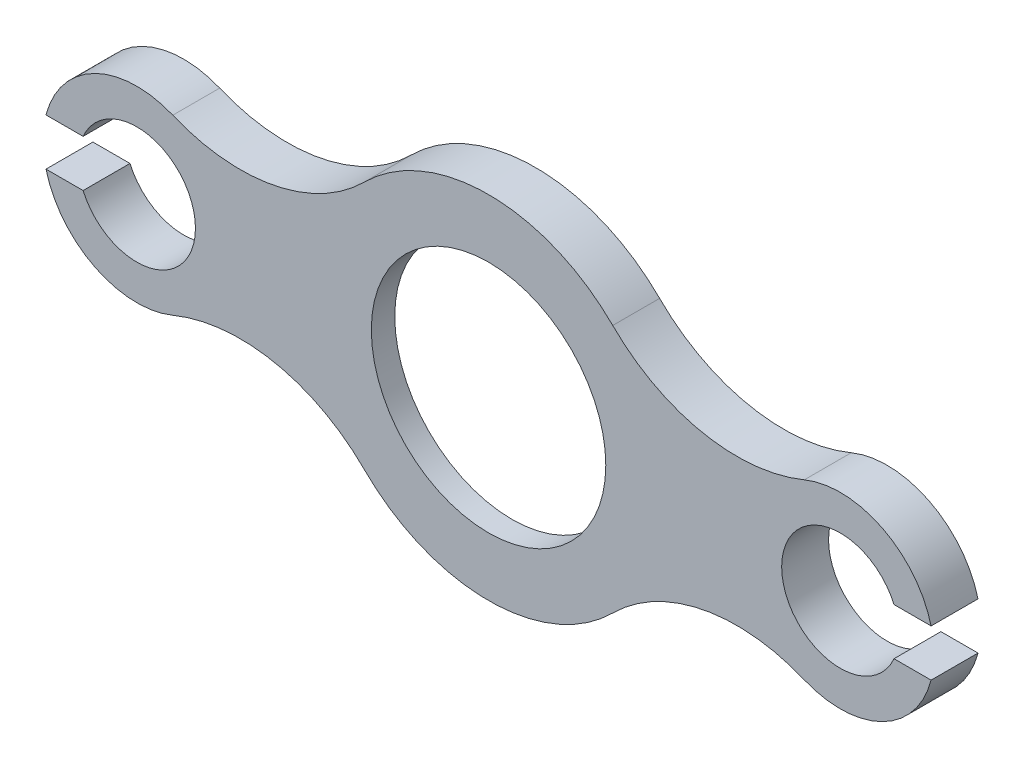
from build123d import *

# Parameters (mm, degrees)
ESQUISSE1_R             = 50
BOSS_EXTRU_1_DEPTH      = 20
ESQUISSE1_3_R           = 67.8
ESQUISSE1_3_R_2         = 50
ENL_V_MAT_EXTRU_1_DEPTH = 10


with BuildPart() as part:
    # Esquisse1 → Boss.-Extru.1 (new body)
    with BuildSketch(Plane.XY):
        with BuildLine():
            Line((-172.912878475, -10), (-188.729833462, -10))
            ThreePointArc((-188.729833462, -10), (-167.842344673, -35.800149952), (-134.666666667, -36.944402673))
            ThreePointArc((-134.666666667, -36.944402673), (-91.362529225, -32.640861336), (-52.958333333, -53.107578843))
            ThreePointArc((-52.958333333, -53.107578843), (0, -75), (52.958333333, -53.107578843))
            ThreePointArc((52.958333333, -53.107578843), (91.362529225, -32.640861336), (134.666666667, -36.944402673))
            ThreePointArc((134.666666667, -36.944402673), (167.842344673, -35.800149952), (188.729833462, -10))
            Line((188.729833462, -10), (172.912878475, -10))
            ThreePointArc((172.912878475, -10), (125, 0), (172.912878475, 10))
            Line((172.912878475, 10), (188.729833462, 10))
            ThreePointArc((188.729833462, 10), (167.842344673, 35.800149952), (134.666666667, 36.944402673))
            ThreePointArc((134.666666667, 36.944402673), (91.362529225, 32.640861336), (52.958333333, 53.107578843))
            ThreePointArc((52.958333333, 53.107578843), (0, 75), (-52.958333333, 53.107578843))
            ThreePointArc((-52.958333333, 53.107578843), (-91.362529225, 32.640861336), (-134.666666667, 36.944402673))
            ThreePointArc((-134.666666667, 36.944402673), (-167.842344673, 35.800149952), (-188.729833462, 10))
            Line((-188.729833462, 10), (-172.912878475, 10))
            ThreePointArc((-172.912878475, 10), (-125, 0), (-172.912878475, -10))
        make_face()
        Circle(ESQUISSE1_R, mode=Mode.SUBTRACT)
    extrude(amount=BOSS_EXTRU_1_DEPTH)

    # Esquisse1_3 → Enl_v. mat.-Extru.1 (cut)
    with BuildSketch(Plane.XY):
        Circle(ESQUISSE1_3_R)
        Circle(ESQUISSE1_3_R_2, mode=Mode.SUBTRACT)
    extrude(amount=ENL_V_MAT_EXTRU_1_DEPTH, mode=Mode.SUBTRACT)


solid = part.part
